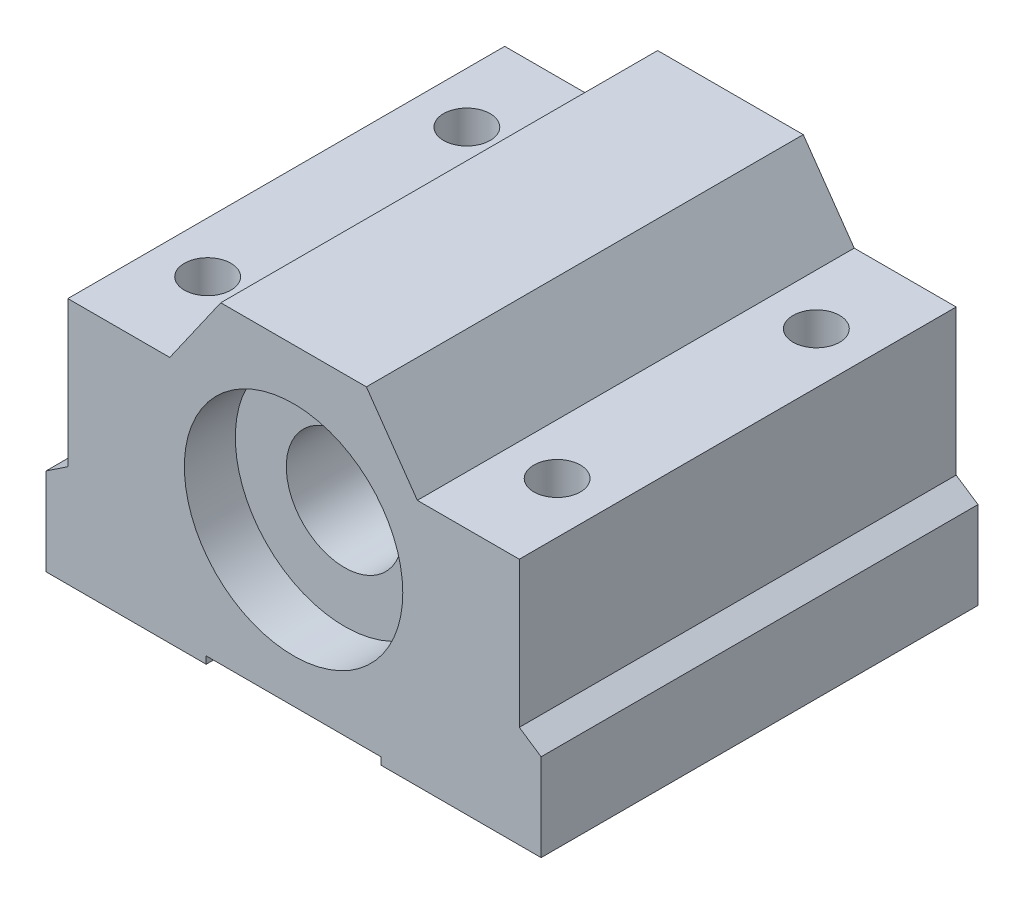
from build123d import *

# Parameters (mm, degrees)
Y_KSEKLIK_EKSTR_ZYON1_DEPTH      = 15
Y_KSEKLIK_EKSTR_ZYON1_DEPTH_BACK = 15
IZIM2_R                          = 7.5
KES_EKSTR_ZYON1_DEPTH            = 37.193922142
Y_KSEKLIK_EKSTR_ZYON2_DEPTH      = 11.5
Y_KSEKLIK_EKSTR_ZYON2_DEPTH_BACK = 11.5
IZIM3_R                          = 7.5
IZIM3_R_2                        = 4
IZIM4_R                          = 1.6
KES_EKSTR_ZYON2_DEPTH            = 29.337254631


with BuildPart() as part:
    # Çizim1 → Yükseklik-Ekstrüzyon1 (new, two sides: drawn at the far end of the back side and taken through both)
    with BuildSketch(Plane.XY.offset(-Y_KSEKLIK_EKSTR_ZYON1_DEPTH_BACK)):
        Polygon((-15.5, 6), (-8.5, 6), (-5, 11), (5, 11), (8.5, 6), (15.5, 6), (15.5, -4), (17, -5), (17, -11), (6, -11), (6, -10.5), (-6, -10.5), (-6, -11), (-17, -11), (-17, -5), (-15.5, -4), align=None)
    extrude(amount=Y_KSEKLIK_EKSTR_ZYON1_DEPTH + Y_KSEKLIK_EKSTR_ZYON1_DEPTH_BACK)

    # Çizim2 → Kes-Ekstrüzyon1 (cut, through all)
    with BuildSketch(Plane.XY.offset(15)):
        Circle(IZIM2_R)
    extrude(amount=-KES_EKSTR_ZYON1_DEPTH, mode=Mode.SUBTRACT)

    # Çizim3 → Yükseklik-Ekstrüzyon2 (add, two sides: drawn at the far end of the back side and taken through both)
    with BuildSketch(Plane.XY.offset(-Y_KSEKLIK_EKSTR_ZYON2_DEPTH_BACK)):
        Circle(IZIM3_R)
        Circle(IZIM3_R_2, mode=Mode.SUBTRACT)
    extrude(amount=Y_KSEKLIK_EKSTR_ZYON2_DEPTH + Y_KSEKLIK_EKSTR_ZYON2_DEPTH_BACK)

    # Çizim4 → Kes-Ekstrüzyon2 (cut, through all)
    with BuildSketch(Plane(origin=(0, 6, 0), x_dir=(1, 0, 0), z_dir=(0, 1, 0))):
        with Locations((-12, 8.9)):
            Circle(IZIM4_R)
        with Locations((-12, -8.9)):
            Circle(IZIM4_R)
        with Locations((12, -8.9)):
            Circle(IZIM4_R)
        with Locations((12, 8.9)):
            Circle(IZIM4_R)
    extrude(amount=-KES_EKSTR_ZYON2_DEPTH, mode=Mode.SUBTRACT)


solid = part.part
